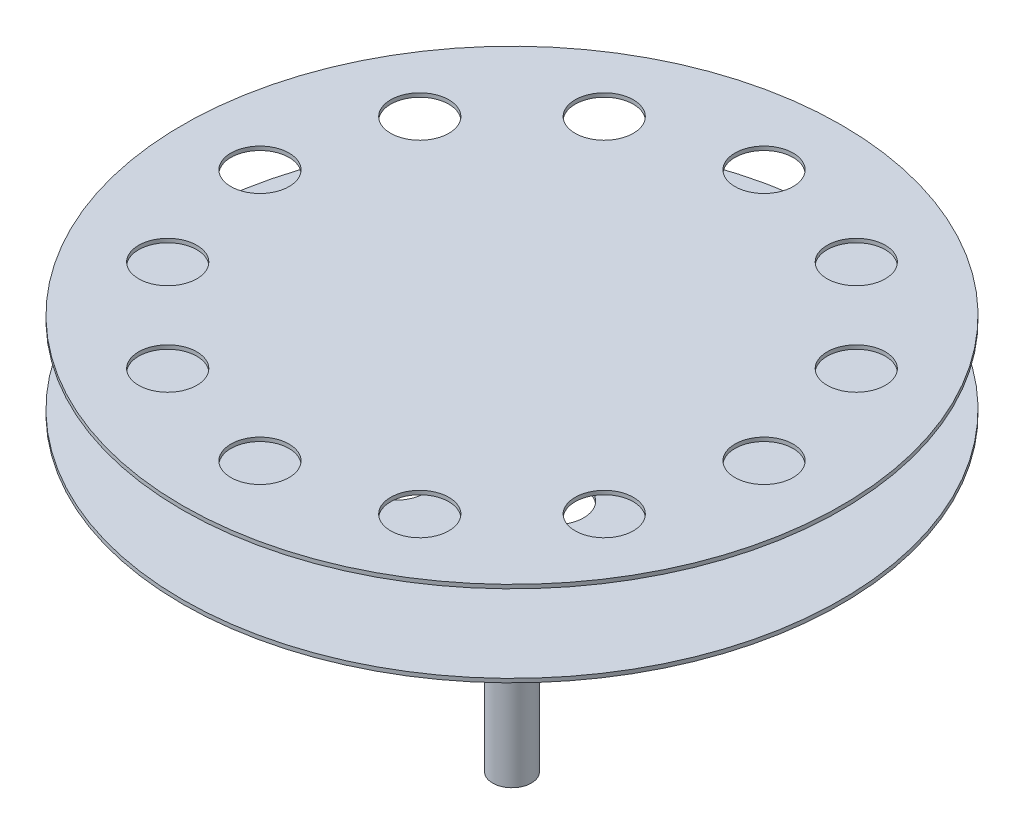
from build123d import *

# Parameters (mm, degrees)
SKETCH2_R          = 7.5
CUT_EXTRUDE1_DEPTH = 2
CIRPATTERN1_COUNT  = 12
SKETCH3_R          = 7.5
CUT_EXTRUDE2_DEPTH = 2
CIRPATTERN2_COUNT  = 6


with BuildPart() as part:
    # Sketch1 → Revolve1 (revolve)
    with BuildSketch(Plane.XY):
        Polygon((0, 102), (-84.99983, 102), (-84.99983, 101), (-5, 101), (-5, 81), (-84.99983, 81), (-84.99983, 80), (-5, 80), (-5, 0), (0, 0), align=None)
    revolve(axis=Axis((0, 54.874193188, 0), (0, -1, 0)))

    # Sketch2 → Cut-Extrude1 (cut)
    with BuildSketch(Plane(origin=(0, 102, 0), x_dir=(1, 0, 0), z_dir=(0, 1, 0))):
        with Locations((0, 65)):
            Circle(SKETCH2_R)
    cut_extrude1 = extrude(amount=-CUT_EXTRUDE1_DEPTH, mode=Mode.SUBTRACT)

    # CirPattern1: Cut-Extrude1 ×12 about axis
    cirpattern1_axis = Axis((0, 0, 0), (0, 1, 0))
    for i in range(1, CIRPATTERN1_COUNT):
        add(cut_extrude1.rotate(cirpattern1_axis, i * 360 / CIRPATTERN1_COUNT), mode=Mode.SUBTRACT)

    # Sketch3 → Cut-Extrude2 (cut)
    with BuildSketch(Plane.XZ.offset(-80)):
        with Locations((0, 30)):
            Circle(SKETCH3_R)
    cut_extrude2 = extrude(amount=-CUT_EXTRUDE2_DEPTH, mode=Mode.SUBTRACT)

    # CirPattern2: Cut-Extrude2 ×6 about axis
    cirpattern2_axis = Axis((0, 0, 0), (0, 1, 0))
    for i in range(1, CIRPATTERN2_COUNT):
        add(cut_extrude2.rotate(cirpattern2_axis, i * 360 / CIRPATTERN2_COUNT), mode=Mode.SUBTRACT)


solid = part.part
